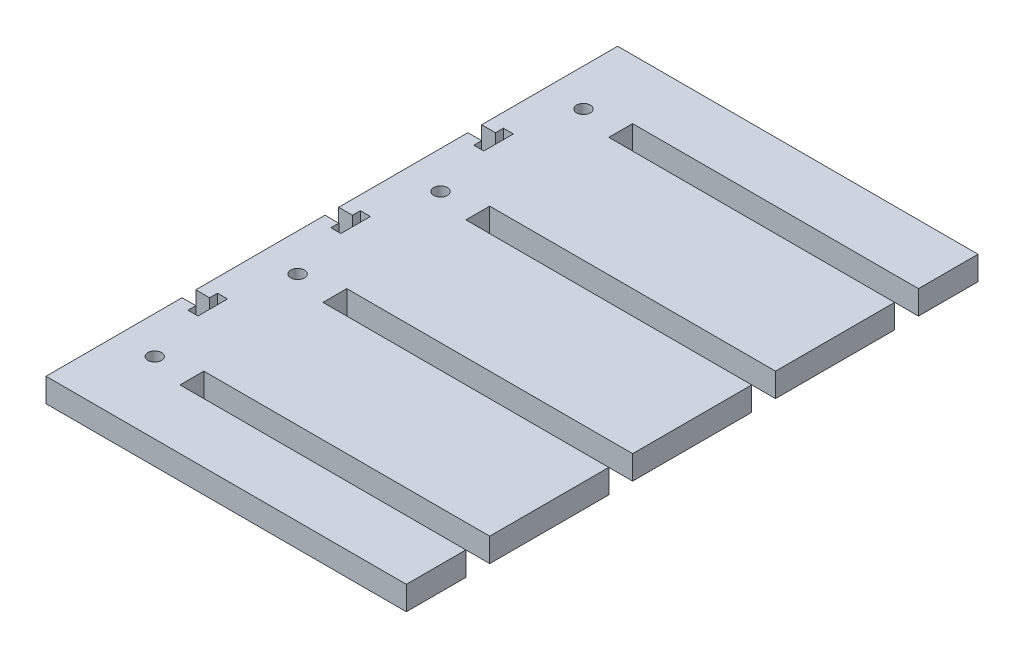
from build123d import *

# Parameters (mm, degrees)
SKETCH1_R           = 1.8288
BOSS_EXTRUDE1_DEPTH = 6.35


with BuildPart() as part:
    # Sketch1 → Boss-Extrude1 (new body)
    with BuildSketch(Plane(origin=(0, 0, 0), x_dir=(1, 0, 0), z_dir=(0, 1, 0))):
        Polygon((-48.0314, 76.2), (48.0314, 76.2), (48.0314, 60.325), (-28.1686, 60.325), (-28.1686, 53.975), (48.0314, 53.975), (48.0314, 22.225), (-28.1686, 22.225), (-28.1686, 15.875), (48.0314, 15.875), (48.0314, -15.875), (-28.1686, -15.875), (-28.1686, -22.225), (48.0314, -22.225), (48.0314, -53.975), (-28.1686, -53.975), (-28.1686, -60.325), (48.0314, -60.325), (48.0314, -76.2), (-48.0314, -76.2), (-48.0314, -39.9288), (-44.3484, -39.9288), (-44.3484, -42.037), (-41.6814, -42.037), (-41.6814, -34.163), (-44.3484, -34.163), (-44.3484, -36.2712), (-48.0314, -36.2712), (-48.0314, -1.8288), (-44.3484, -1.8288), (-44.3484, -3.937), (-41.6814, -3.937), (-41.6814, 3.937), (-44.3484, 3.937), (-44.3484, 1.8288), (-48.0314, 1.8288), (-48.0314, 36.2712), (-44.3484, 36.2712), (-44.3484, 34.163), (-41.6814, 34.163), (-41.6814, 42.037), (-44.3484, 42.037), (-44.3484, 39.9288), (-48.0314, 39.9288), align=None)
        with Locations((-38.1, 57.15)):
            Circle(SKETCH1_R, mode=Mode.SUBTRACT)
        with Locations((-38.1, 19.05)):
            Circle(SKETCH1_R, mode=Mode.SUBTRACT)
        with Locations((-38.1, -19.05)):
            Circle(SKETCH1_R, mode=Mode.SUBTRACT)
        with Locations((-38.1, -57.15)):
            Circle(SKETCH1_R, mode=Mode.SUBTRACT)
    extrude(amount=-BOSS_EXTRUDE1_DEPTH)


solid = part.part
